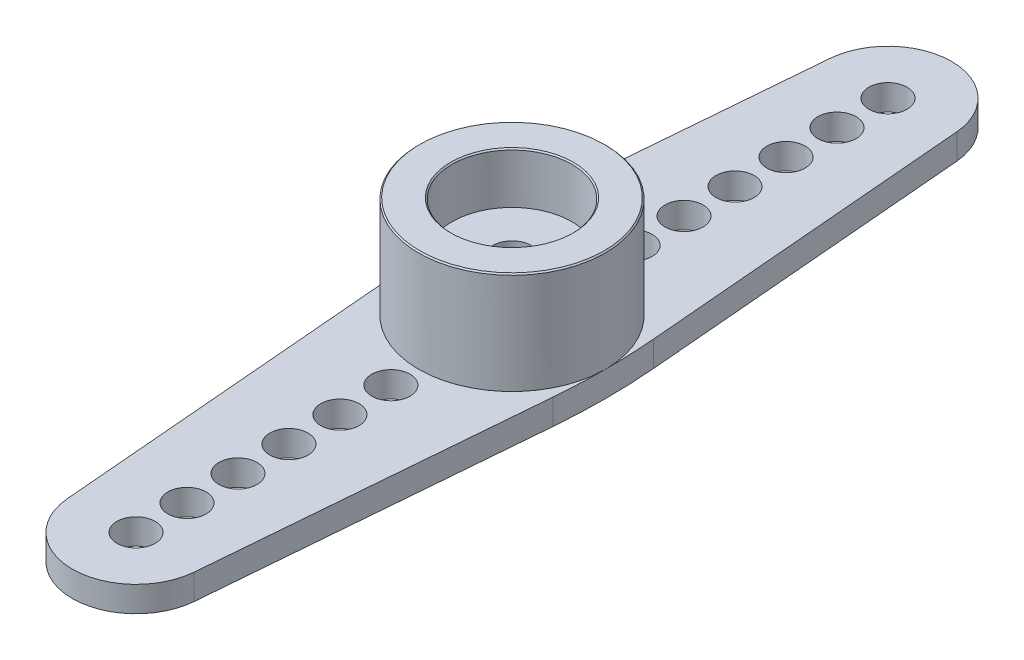
from build123d import *

# Parameters (mm, degrees)
SKETCH1_R           = 0.75
BOSS_EXTRUDE1_DEPTH = 1
SKETCH2_R           = 3.666938222
SKETCH2_R_2         = 0.75
BOSS_EXTRUDE2_DEPTH = 5
SKETCH2_2_R         = 1.5
CUT_EXTRUDE1_DEPTH  = 0.5
SKETCH3_R           = 2.355
CUT_EXTRUDE2_DEPTH  = 2
CHAMFER1_SIZE       = 0.05


with BuildPart() as part:
    # Sketch1 → Boss-Extrude1 (new body)
    with BuildSketch(Plane(origin=(0, 0, 0), x_dir=(1, 0, 0), z_dir=(0, 1, 0))):
        with BuildLine():
            Line((-2.49119588, 14.959626071), (-3.584168958, 1.970735827))
            ThreePointArc((-3.584168958, 1.970735827), (-3.666938222, 0), (-3.584168958, -1.970735827))
            Line((-3.584168958, -1.970735827), (-2.49119588, -14.959626071))
            ThreePointArc((-2.49119588, -14.959626071), (0, -17.25), (2.49119588, -14.959626071))
            Line((2.49119588, -14.959626071), (3.584168958, -1.970735827))
            ThreePointArc((3.584168958, -1.970735827), (3.666938222, 0), (3.584168958, 1.970735827))
            Line((3.584168958, 1.970735827), (2.49119588, 14.959626071))
            ThreePointArc((2.49119588, 14.959626071), (0, 17.25), (-2.49119588, 14.959626071))
        make_face()
        with Locations((0, 14.75)):
            Circle(SKETCH1_R, mode=Mode.SUBTRACT)
        with Locations((0, 12.75)):
            Circle(SKETCH1_R, mode=Mode.SUBTRACT)
        with Locations((0, 10.75)):
            Circle(SKETCH1_R, mode=Mode.SUBTRACT)
        with Locations((0, 8.75)):
            Circle(SKETCH1_R, mode=Mode.SUBTRACT)
        with Locations((0, 6.75)):
            Circle(SKETCH1_R, mode=Mode.SUBTRACT)
        with Locations((0, 4.75)):
            Circle(SKETCH1_R, mode=Mode.SUBTRACT)
        Circle(SKETCH1_R, mode=Mode.SUBTRACT)
        with Locations((0, -14.75)):
            Circle(SKETCH1_R, mode=Mode.SUBTRACT)
        with Locations((0, -12.75)):
            Circle(SKETCH1_R, mode=Mode.SUBTRACT)
        with Locations((0, -10.75)):
            Circle(SKETCH1_R, mode=Mode.SUBTRACT)
        with Locations((0, -8.75)):
            Circle(SKETCH1_R, mode=Mode.SUBTRACT)
        with Locations((0, -6.75)):
            Circle(SKETCH1_R, mode=Mode.SUBTRACT)
        with Locations((0, -4.75)):
            Circle(SKETCH1_R, mode=Mode.SUBTRACT)
    extrude(amount=BOSS_EXTRUDE1_DEPTH)

    # Sketch2 → Boss-Extrude2 (add)
    with BuildSketch(Plane.XZ):
        Circle(SKETCH2_R)
        Circle(SKETCH2_R_2, mode=Mode.SUBTRACT)
    extrude(amount=-BOSS_EXTRUDE2_DEPTH)

    # Sketch2_2 → Cut-Extrude1 (cut)
    with BuildSketch(Plane.XZ):
        Circle(SKETCH2_2_R)
    extrude(amount=-CUT_EXTRUDE1_DEPTH, mode=Mode.SUBTRACT)

    # Sketch3 → Cut-Extrude2 (cut)
    with BuildSketch(Plane(origin=(0, 5, 0), x_dir=(1, 0, 0), z_dir=(0, 1, 0))):
        Circle(SKETCH3_R)
    extrude(amount=-CUT_EXTRUDE2_DEPTH, mode=Mode.SUBTRACT)

    # Chamfer1
    chamfer1_edges = [part.edges().sort_by_distance(p)[0] for p in [
        (-3.666938222, 5, 0),
        (-2.355, 5, 0),
    ]]
    chamfer(chamfer1_edges, length=CHAMFER1_SIZE)


solid = part.part
